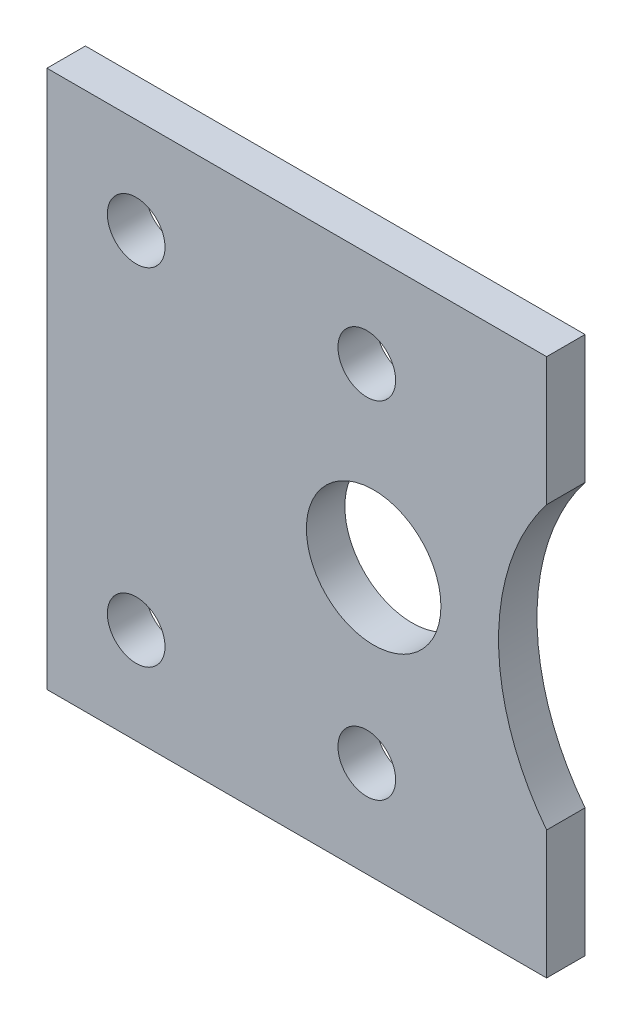
from build123d import *

# Parameters (mm, degrees)
SKETCH1_R           = 1.5
SKETCH1_R_2         = 3.5
BOSS_EXTRUDE1_DEPTH = 2


with BuildPart() as part:
    # Sketch1 → Boss-Extrude1 (new body)
    with BuildSketch(Plane.XY):
        with BuildLine():
            Line((-13, -14), (13, -14))
            Line((13, -14), (13, -7.331439149))
            ThreePointArc((13, -7.331439149), (10.5, 0), (13, 7.331439149))
            Line((13, 7.331439149), (13, 14))
            Line((13, 14), (-13, 14))
            Line((-13, 14), (-13, -14))
        make_face()
        with Locations((-8.357142857, 9)):
            Circle(SKETCH1_R, mode=Mode.SUBTRACT)
        with Locations((4, 0)):
            Circle(SKETCH1_R_2, mode=Mode.SUBTRACT)
        with Locations((3.642857143, 9)):
            Circle(SKETCH1_R, mode=Mode.SUBTRACT)
        with Locations((3.642857143, -9)):
            Circle(SKETCH1_R, mode=Mode.SUBTRACT)
        with Locations((-8.357142857, -9)):
            Circle(SKETCH1_R, mode=Mode.SUBTRACT)
    extrude(amount=BOSS_EXTRUDE1_DEPTH)


solid = part.part
